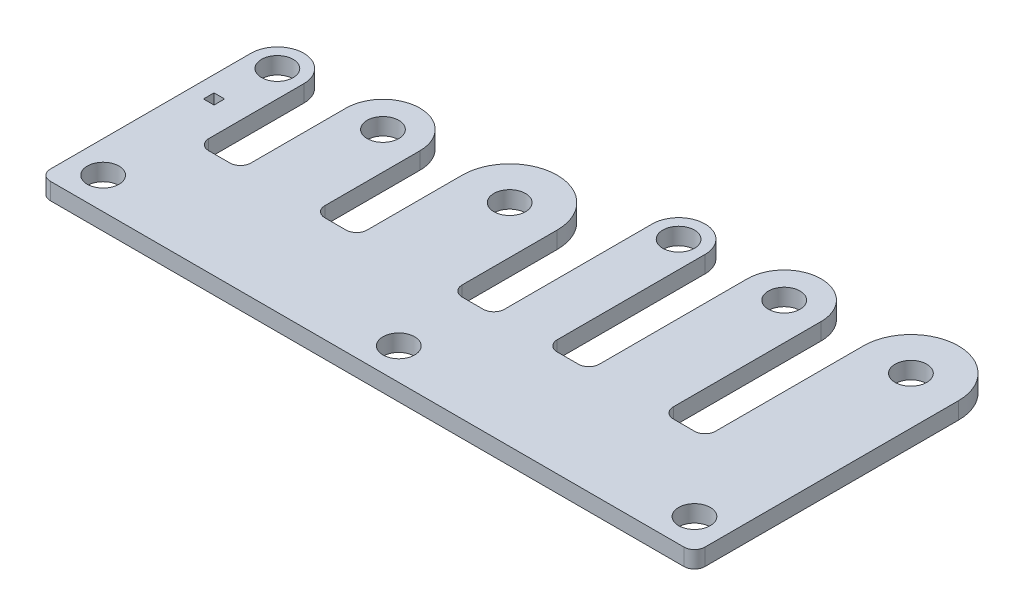
from build123d import *

# Parameters (mm, degrees)
SKETCH1_R           = 1.5
SKETCH1_W           = 1
SKETCH1_H           = 1
BOSS_EXTRUDE1_DEPTH = 1.6
FILLET1_R           = 1


with BuildPart() as part:
    # Sketch1 → Boss-Extrude1 (new body)
    with BuildSketch(Plane(origin=(0, 0, 0), x_dir=(1, 0, 0), z_dir=(0, 1, 0))):
        with BuildLine():
            ThreePointArc((13.5, 5), (10, 8.5), (6.5, 5))
            Line((6.5, 5), (6.5, -5))
            Line((6.5, -5), (2.5, -5))
            Line((2.5, -5), (2.5, 5))
            ThreePointArc((2.5, 5), (0, 7.5), (-2.5, 5))
            Line((-2.5, 5), (-2.5, -15))
            Line((-2.5, -15), (59.5, -15))
            Line((59.5, -15), (59.5, 10))
            ThreePointArc((59.5, 10), (55, 14.5), (50.5, 10))
            Line((50.5, 10), (50.5, -5))
            Line((50.5, -5), (46.5, -5))
            Line((46.5, -5), (46.5, 10))
            ThreePointArc((46.5, 10), (43, 13.5), (39.5, 10))
            Line((39.5, 10), (39.5, -5))
            Line((39.5, -5), (35.5, -5))
            Line((35.5, -5), (35.5, 10))
            ThreePointArc((35.5, 10), (33, 12.5), (30.5, 10))
            Line((30.5, 10), (30.5, -5))
            Line((30.5, -5), (26.5, -5))
            Line((26.5, -5), (26.5, 5))
            ThreePointArc((26.5, 5), (22, 9.5), (17.5, 5))
            Line((17.5, 5), (17.5, -5))
            Line((17.5, -5), (13.5, -5))
            Line((13.5, -5), (13.5, 5))
        make_face()
        with Locations((10, 5)):
            Circle(SKETCH1_R, mode=Mode.SUBTRACT)
        with Locations((56.5, -12)):
            Circle(SKETCH1_R, mode=Mode.SUBTRACT)
        with Locations((0.5, -12)):
            Circle(SKETCH1_R, mode=Mode.SUBTRACT)
        with Locations((28.5, -12)):
            Circle(SKETCH1_R, mode=Mode.SUBTRACT)
        with Locations((0, 5)):
            Circle(SKETCH1_R, mode=Mode.SUBTRACT)
        with Locations((-0.5, -0.5)):
            Rectangle(SKETCH1_W, SKETCH1_H, mode=Mode.SUBTRACT)
        with Locations((22, 5)):
            Circle(SKETCH1_R, mode=Mode.SUBTRACT)
        with Locations((33, 10)):
            Circle(SKETCH1_R, mode=Mode.SUBTRACT)
        with Locations((55, 10)):
            Circle(SKETCH1_R, mode=Mode.SUBTRACT)
        with Locations((43, 10)):
            Circle(SKETCH1_R, mode=Mode.SUBTRACT)
    extrude(amount=BOSS_EXTRUDE1_DEPTH)

    # Fillet1
    fillet1_edges = [part.edges().sort_by_distance(p)[0] for p in [
        (2.5, 0.8, 5),
        (6.5, 0.8, 5),
        (13.5, 0.8, 5),
        (17.5, 0.8, 5),
        (26.5, 0.8, 5),
        (30.5, 0.8, 5),
        (35.5, 0.8, 5),
        (39.5, 0.8, 5),
        (46.5, 0.8, 5),
        (50.5, 0.8, 5),
        (59.5, 0.8, 15),
        (-2.5, 0.8, 15),
    ]]
    fillet(fillet1_edges, radius=FILLET1_R)


solid = part.part
